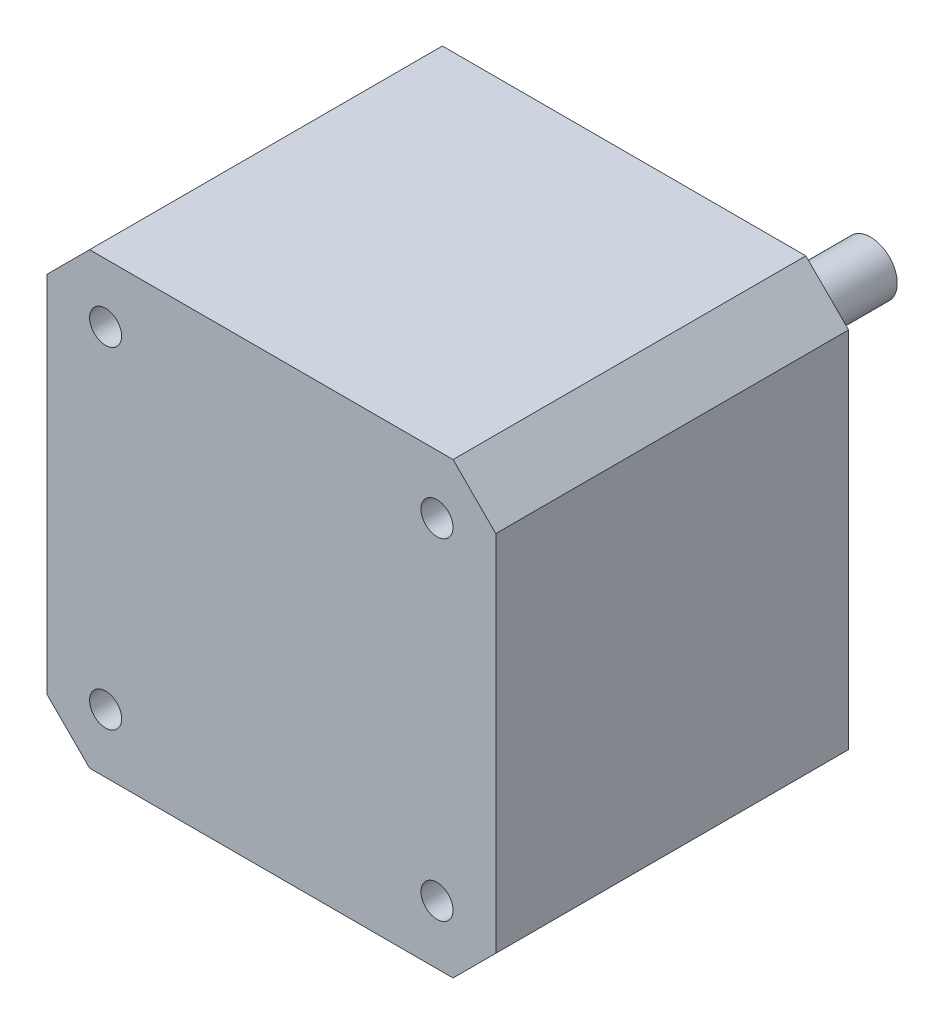
from build123d import *

# Parameters (mm, degrees)
SZKIC1_W                    = 42
SZKIC1_H                    = 42
DODANIE_WYCI_GNI_CIE1_DEPTH = 33
SFAZOWANIE1_SIZE            = 4
SZKIC2_R                    = 11
DODANIE_WYCI_GNI_CIE2_DEPTH = 1.3
SZKIC3_R                    = 2.5
DODANIE_WYCI_GNI_CIE3_DEPTH = 21.75
SZKIC4_R                    = 1.5
WYTNIJ_WYCI_GNI_CIE1_DEPTH  = 34


with BuildPart() as part:
    # Szkic1 → Dodanie-wyciągnięcie1 (new body)
    with BuildSketch(Plane.XY):
        Rectangle(SZKIC1_W, SZKIC1_H)
    extrude(amount=DODANIE_WYCI_GNI_CIE1_DEPTH)

    # Sfazowanie1
    sfazowanie1_edges = [part.edges().sort_by_distance(p)[0] for p in [
        (21, -21, 16.5),
        (-21, -21, 16.5),
        (-21, 21, 16.5),
        (21, 21, 16.5),
    ]]
    chamfer(sfazowanie1_edges, length=SFAZOWANIE1_SIZE)

    # Szkic2 → Dodanie-wyciągnięcie2 (add)
    with BuildSketch(Plane(origin=(0, 0, 0), x_dir=(-1, 0, 0), z_dir=(0, 0, -1))):
        Circle(SZKIC2_R)
    extrude(amount=DODANIE_WYCI_GNI_CIE2_DEPTH)

    # Szkic3 → Dodanie-wyciągnięcie3 (add)
    with BuildSketch(Plane(origin=(0, 0, -1.3), x_dir=(-1, 0, 0), z_dir=(0, 0, -1))):
        Circle(SZKIC3_R)
    extrude(amount=DODANIE_WYCI_GNI_CIE3_DEPTH)

    # Szkic4 → Wytnij-wyciągnięcie1 (cut, through all)
    with BuildSketch(Plane(origin=(0, 0, 0), x_dir=(-1, 0, 0), z_dir=(0, 0, -1))):
        with Locations((15.5, 15.5)):
            Circle(SZKIC4_R)
        with Locations((-15.5, 15.5)):
            Circle(SZKIC4_R)
        with Locations((-15.5, -15.5)):
            Circle(SZKIC4_R)
        with Locations((15.5, -15.5)):
            Circle(SZKIC4_R)
    extrude(amount=-WYTNIJ_WYCI_GNI_CIE1_DEPTH, mode=Mode.SUBTRACT)


solid = part.part
